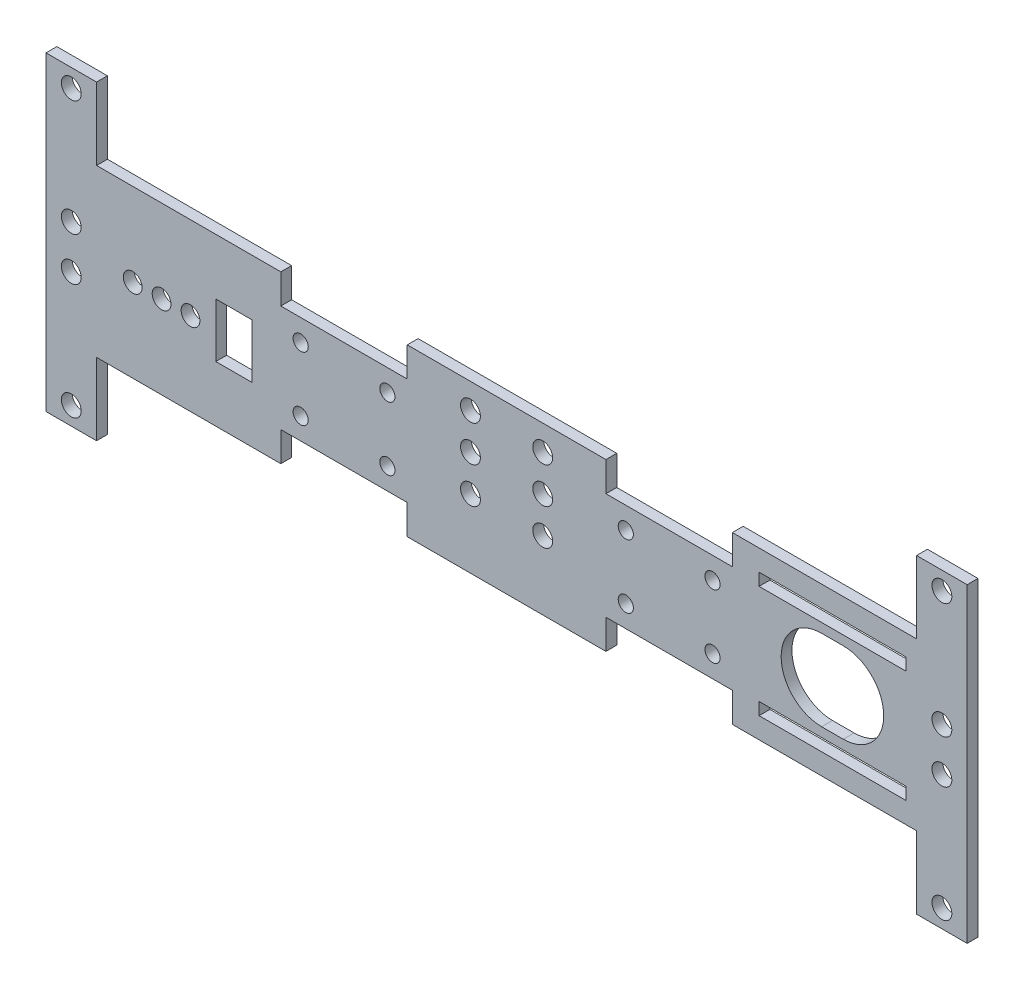
from build123d import *

# Parameters (mm, degrees)
ESQUISSE1_R             = 2.75
ESQUISSE1_R_2           = 2.6
ESQUISSE1_R_3           = 2.1
ESQUISSE1_W             = 40.6
ESQUISSE1_H             = 3.4
ESQUISSE1_W_2           = 10
ESQUISSE1_H_2           = 15
BOSS_EXTRU_1_DEPTH      = 3
ENL_V_MAT_EXTRU_1_REACH = 5
ESQUISSE2_W             = 35
ESQUISSE2_H             = 8.195


with BuildPart() as part:
    # Esquisse1 → Boss.-Extru.1 (new body)
    with BuildSketch(Plane(origin=(0, 0, 0), x_dir=(-1, 0, 0), z_dir=(0, 0, -1))):
        Polygon((-14, 66), (-241, 66), (-241, 86), (-255, 86), (-255, 20), (-255, 0), (-241, 0), (-241, 20), (-14, 20), (-14, 0), (0, 0), (0, 86), (-14, 86), align=None)
        with Locations((-7, 81)):
            Circle(ESQUISSE1_R, mode=Mode.SUBTRACT)
        with Locations((-32, 43)):
            Circle(ESQUISSE1_R_2, mode=Mode.SUBTRACT)
        with Locations((-40, 43)):
            Circle(ESQUISSE1_R_2, mode=Mode.SUBTRACT)
        with Locations((-137.5, 39)):
            Circle(ESQUISSE1_R, mode=Mode.SUBTRACT)
        with Locations((-117.5, 39)):
            Circle(ESQUISSE1_R, mode=Mode.SUBTRACT)
        with Locations((-137.5, 59)):
            Circle(ESQUISSE1_R, mode=Mode.SUBTRACT)
        with Locations((-117.5, 59)):
            Circle(ESQUISSE1_R, mode=Mode.SUBTRACT)
        with Locations((-94.5, 51.805)):
            Circle(ESQUISSE1_R_3, mode=Mode.SUBTRACT)
        with Locations((-248, 37)):
            Circle(ESQUISSE1_R, mode=Mode.SUBTRACT)
        with Locations((-248, 5)):
            Circle(ESQUISSE1_R, mode=Mode.SUBTRACT)
        with Locations((-248, 49.000000164)):
            Circle(ESQUISSE1_R, mode=Mode.SUBTRACT)
        with Locations((-117.5, 49)):
            Circle(ESQUISSE1_R, mode=Mode.SUBTRACT)
        with Locations((-137.5, 49)):
            Circle(ESQUISSE1_R, mode=Mode.SUBTRACT)
        with Locations((-160.5, 51.805)):
            Circle(ESQUISSE1_R_3, mode=Mode.SUBTRACT)
        with Locations((-94.5, 34.195)):
            Circle(ESQUISSE1_R_3, mode=Mode.SUBTRACT)
        with Locations((-70.5, 34.195)):
            Circle(ESQUISSE1_R_3, mode=Mode.SUBTRACT)
        with Locations((-70.5, 51.805)):
            Circle(ESQUISSE1_R_3, mode=Mode.SUBTRACT)
        with Locations((-184.5, 34.195)):
            Circle(ESQUISSE1_R_3, mode=Mode.SUBTRACT)
        with Locations((-7, 37)):
            Circle(ESQUISSE1_R, mode=Mode.SUBTRACT)
        with Locations((-248, 81)):
            Circle(ESQUISSE1_R, mode=Mode.SUBTRACT)
        with Locations((-24, 43)):
            Circle(ESQUISSE1_R_2, mode=Mode.SUBTRACT)
        with Locations((-184.5, 51.805)):
            Circle(ESQUISSE1_R_3, mode=Mode.SUBTRACT)
        with Locations((-7, 5)):
            Circle(ESQUISSE1_R, mode=Mode.SUBTRACT)
        with Locations((-7, 49.000000164)):
            Circle(ESQUISSE1_R, mode=Mode.SUBTRACT)
        with Locations((-160.5, 34.195)):
            Circle(ESQUISSE1_R_3, mode=Mode.SUBTRACT)
        with Locations((-217.7, 58.5)):
            Rectangle(ESQUISSE1_W, ESQUISSE1_H, mode=Mode.SUBTRACT)
        with BuildLine():
            Line((-214.7, 31.8), (-220.7, 31.8))
            ThreePointArc((-220.7, 31.8), (-231.9, 43), (-220.7, 54.2))
            Line((-220.7, 54.2), (-214.7, 54.2))
            ThreePointArc((-214.7, 54.2), (-203.5, 43), (-214.7, 31.8))
        make_face(mode=Mode.SUBTRACT)
        with Locations((-217.7, 27.5)):
            Rectangle(ESQUISSE1_W, ESQUISSE1_H, mode=Mode.SUBTRACT)
        with Locations((-52, 43)):
            Rectangle(ESQUISSE1_W_2, ESQUISSE1_H_2, mode=Mode.SUBTRACT)
    extrude(amount=-BOSS_EXTRU_1_DEPTH)

    # Esquisse2 → Enlèv. mat.-Extru.1 (cut, up to next)
    with BuildSketch(Plane.XY.offset(3), mode=Mode.PRIVATE) as enl_v_mat_extru_1_sk1:
        with Locations((82.5, 61.9025)):
            Rectangle(ESQUISSE2_W, ESQUISSE2_H)
    enl_v_mat_extru_1_tool1 = extrude(enl_v_mat_extru_1_sk1.sketch, amount=-ENL_V_MAT_EXTRU_1_REACH, mode=Mode.PRIVATE) & part.part
    add(enl_v_mat_extru_1_tool1.solids().sort_by_distance((82.5, 61.9025, 3))[0], mode=Mode.SUBTRACT)
    # Esquisse2 → Enlèv. mat.-Extru.1 (cut, up to next)
    with BuildSketch(Plane.XY.offset(3), mode=Mode.PRIVATE) as enl_v_mat_extru_1_sk2:
        with Locations((82.5, 24.0975)):
            Rectangle(ESQUISSE2_W, ESQUISSE2_H)
    enl_v_mat_extru_1_tool2 = extrude(enl_v_mat_extru_1_sk2.sketch, amount=-ENL_V_MAT_EXTRU_1_REACH, mode=Mode.PRIVATE) & part.part
    add(enl_v_mat_extru_1_tool2.solids().sort_by_distance((82.5, 24.0975, 3))[0], mode=Mode.SUBTRACT)
    # Esquisse2 → Enlèv. mat.-Extru.1 (cut, up to next)
    with BuildSketch(Plane.XY.offset(3), mode=Mode.PRIVATE) as enl_v_mat_extru_1_sk3:
        with Locations((172.5, 24.0975)):
            Rectangle(ESQUISSE2_W, ESQUISSE2_H)
    enl_v_mat_extru_1_tool3 = extrude(enl_v_mat_extru_1_sk3.sketch, amount=-ENL_V_MAT_EXTRU_1_REACH, mode=Mode.PRIVATE) & part.part
    add(enl_v_mat_extru_1_tool3.solids().sort_by_distance((172.5, 24.0975, 3))[0], mode=Mode.SUBTRACT)
    # Esquisse2 → Enlèv. mat.-Extru.1 (cut, up to next)
    with BuildSketch(Plane.XY.offset(3), mode=Mode.PRIVATE) as enl_v_mat_extru_1_sk4:
        with Locations((172.5, 61.9025)):
            Rectangle(ESQUISSE2_W, ESQUISSE2_H)
    enl_v_mat_extru_1_tool4 = extrude(enl_v_mat_extru_1_sk4.sketch, amount=-ENL_V_MAT_EXTRU_1_REACH, mode=Mode.PRIVATE) & part.part
    add(enl_v_mat_extru_1_tool4.solids().sort_by_distance((172.5, 61.9025, 3))[0], mode=Mode.SUBTRACT)


solid = part.part
